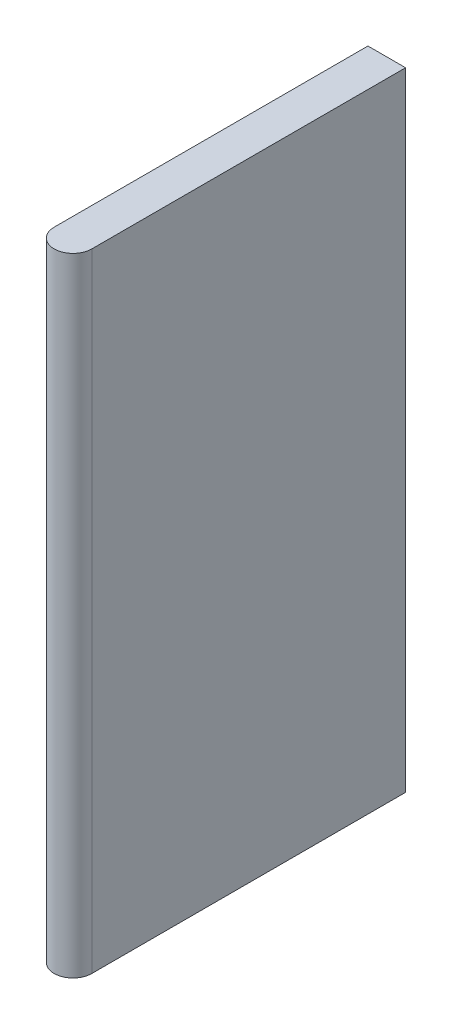
from build123d import *

# Parameters (mm, degrees)
BOSS_EXTRUDE1_DEPTH = 12.7


with BuildPart() as part:
    # Sketch1 → Boss-Extrude1 (new body)
    with BuildSketch(Plane(origin=(0, 0, 0), x_dir=(1, 0, 0), z_dir=(0, 1, 0))):
        with BuildLine():
            Line((-0.381, -3.175), (-0.381, 3.175))
            Line((-0.381, 3.175), (0.381, 3.175))
            Line((0.381, 3.175), (0.381, -3.175))
            ThreePointArc((0.381, -3.175), (0, -3.556), (-0.381, -3.175))
        make_face()
    extrude(amount=BOSS_EXTRUDE1_DEPTH)


solid = part.part
